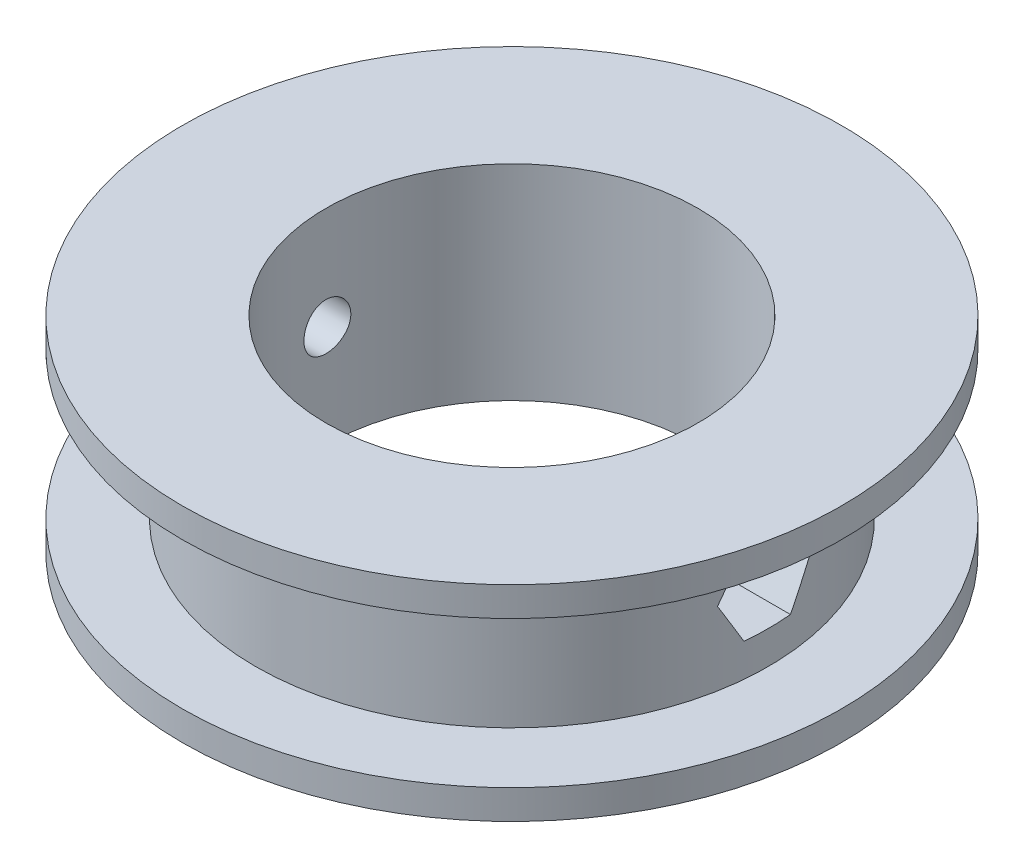
from build123d import *

# Parameters (mm, degrees)
SKETCH1_R           = 17.5
SKETCH1_R_2         = 12.7
BOSS_EXTRUDE1_DEPTH = 5
SKETCH2_R           = 22.5
SKETCH2_R_2         = 12.7
BOSS_EXTRUDE2_DEPTH = 2
SKETCH3_R           = 1.6
CUT_EXTRUDE1_DEPTH  = 23.5
CUT_EXTRUDE2_DEPTH  = 23.5
SKETCH5_R           = 2.75
CUT_EXTRUDE3_DEPTH  = 8.5


with BuildPart() as part:
    # Sketch1 → Boss-Extrude1 (new body, symmetric)
    with BuildSketch(Plane(origin=(0, 0, 0), x_dir=(1, 0, 0), z_dir=(0, 1, 0))):
        Circle(SKETCH1_R)
        Circle(SKETCH1_R_2, mode=Mode.SUBTRACT)
    extrude(amount=BOSS_EXTRUDE1_DEPTH, both=True)

    # Sketch2 → Boss-Extrude2 (add)
    with BuildSketch(Plane(origin=(0, 5, 0), x_dir=(1, 0, 0), z_dir=(0, 1, 0))):
        Circle(SKETCH2_R)
        Circle(SKETCH2_R_2, mode=Mode.SUBTRACT)
    boss_extrude2 = extrude(amount=BOSS_EXTRUDE2_DEPTH)

    # Mirror1: Boss-Extrude2 across plane
    add(boss_extrude2.mirror(Plane.ZX))

    # Sketch3 → Cut-Extrude1 (cut, through all)
    with BuildSketch(Plane(origin=(0, 0, 0), x_dir=(0, 0, -1), z_dir=(1, 0, 0))):
        Circle(SKETCH3_R)
    extrude(amount=-CUT_EXTRUDE1_DEPTH, mode=Mode.SUBTRACT)

    # Sketch4 → Cut-Extrude2 (cut, through all)
    with BuildSketch(Plane(origin=(0, 0, 0), x_dir=(0, 0, -1), z_dir=(1, 0, 0))):
        Polygon((3.175426481, 0), (1.58771324, 2.75), (-1.58771324, 2.75), (-3.175426481, 0), (-1.58771324, -2.75), (1.58771324, -2.75), align=None)
    extrude(amount=CUT_EXTRUDE2_DEPTH, mode=Mode.SUBTRACT)

    # Sketch5 → Cut-Extrude3 (cut, through all)
    with BuildSketch(Plane(origin=(-15, 0, 0), x_dir=(0, 0, -1), z_dir=(1, 0, 0))):
        Circle(SKETCH5_R)
    extrude(amount=-CUT_EXTRUDE3_DEPTH, mode=Mode.SUBTRACT)


solid = part.part
